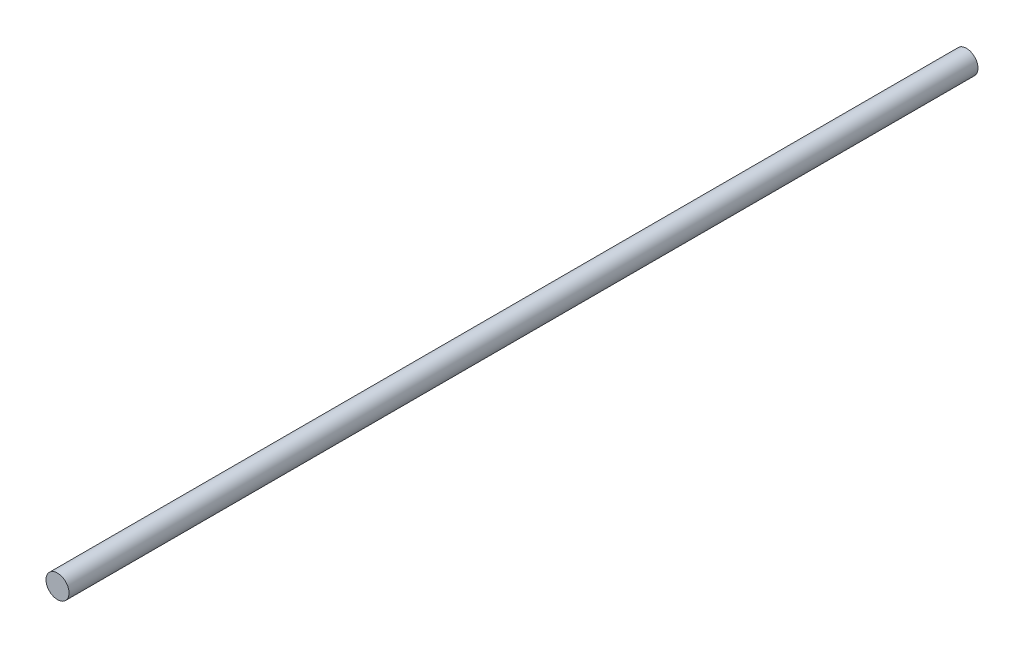
from build123d import *

# Parameters (mm, degrees)
SKETCH1_R = 0.5
ROD_DEPTH = 39.44


with BuildPart() as part:
    # Sketch1 → Rod (new body)
    with BuildSketch(Plane.XY):
        Circle(SKETCH1_R)
    extrude(amount=ROD_DEPTH)


solid = part.part
